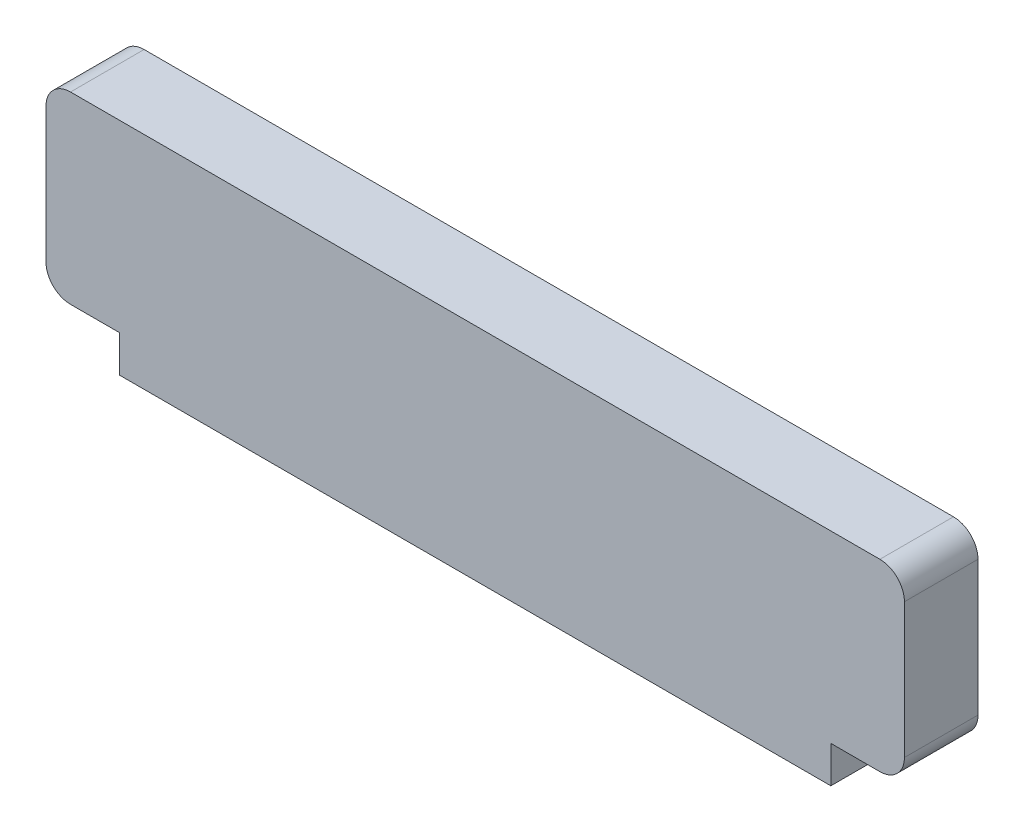
from build123d import *

# Parameters (mm, degrees)
SKETCH_1_W      = 70
SKETCH_1_H      = 15
EXTRUDE_1_DEPTH = 6
FILLET_1_R      = 2
SKETCH_2_W      = 58
SKETCH_2_H      = 6
EXTRUDE_2_DEPTH = 3


with BuildPart() as part:
    # Эскиз1 → Бобышка-Вытянуть1 (new body)
    with BuildSketch(Plane.XY):
        with Locations((35, 7.5)):
            Rectangle(SKETCH_1_W, SKETCH_1_H)
    extrude(amount=EXTRUDE_1_DEPTH)

    # Скругление1
    fillet_1_edges = [part.edges().sort_by_distance(p)[0] for p in [
        (0, 15, 3),
        (70, 15, 3),
        (70, 0, 3),
        (0, 0, 3),
    ]]
    fillet(fillet_1_edges, radius=FILLET_1_R)

    # Эскиз2 → Бобышка-Вытянуть2 (add)
    with BuildSketch(Plane.XZ):
        with Locations((35, 3)):
            Rectangle(SKETCH_2_W, SKETCH_2_H)
    extrude(amount=EXTRUDE_2_DEPTH)


solid = part.part
